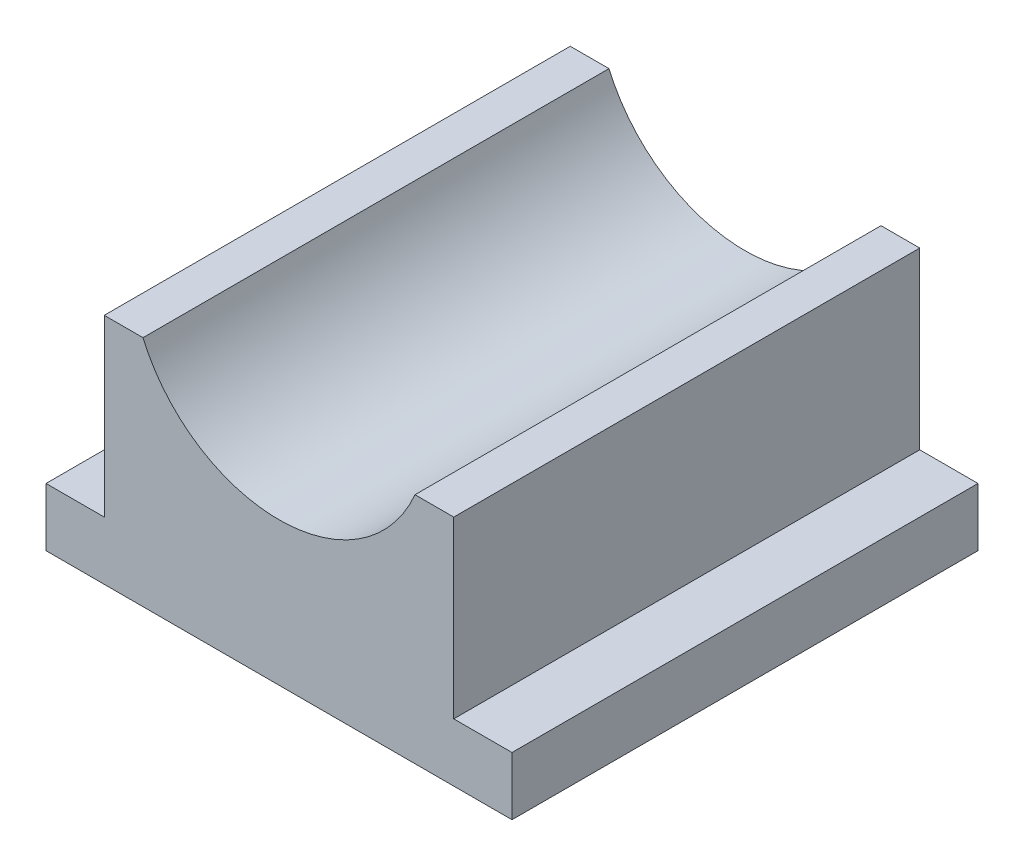
from build123d import *

# Parameters (mm, degrees)
BOSS_EXTRUDE1_DEPTH = 101.6


with BuildPart() as part:
    # Sketch1 → Boss-Extrude1 (new body)
    with BuildSketch(Plane.XY):
        with BuildLine():
            Line((-50.8, -63.5), (50.8, -63.5))
            Line((50.8, -63.5), (50.8, -50.8))
            Line((50.8, -50.8), (38.1, -50.8))
            Line((38.1, -50.8), (38.1, -12.7))
            Line((38.1, -12.7), (29.652800272, -12.7))
            ThreePointArc((29.652800272, -12.7), (0, -32.258), (-29.652800272, -12.7))
            Line((-29.652800272, -12.7), (-38.1, -12.7))
            Line((-38.1, -12.7), (-38.1, -50.8))
            Line((-38.1, -50.8), (-50.8, -50.8))
            Line((-50.8, -50.8), (-50.8, -63.5))
        make_face()
    extrude(amount=BOSS_EXTRUDE1_DEPTH)


solid = part.part
